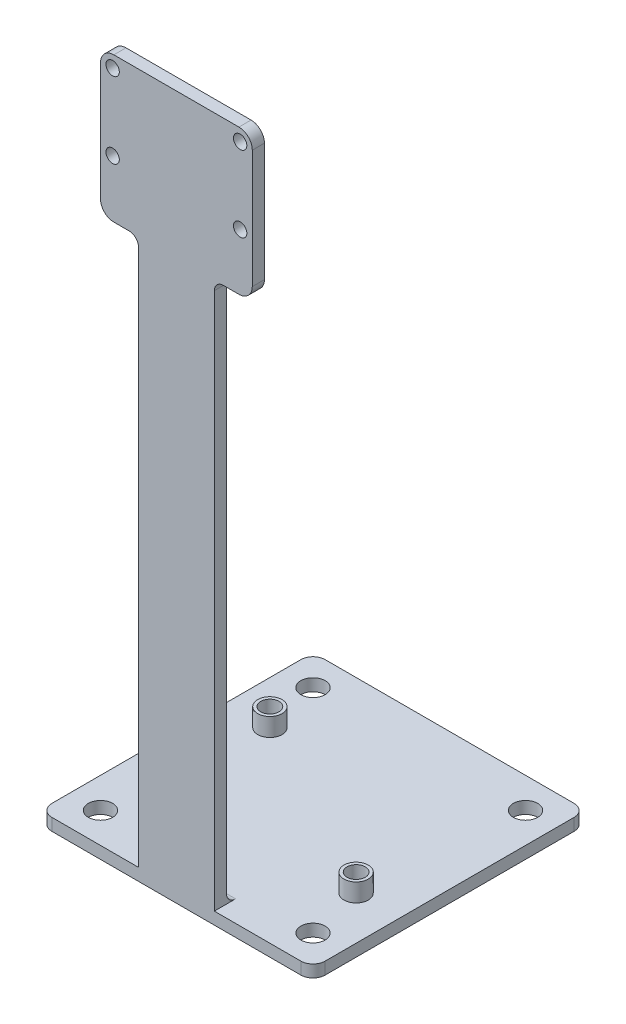
from build123d import *

# Parameters (mm, degrees)
SKETCH1_R           = 1.1
BOSS_EXTRUDE1_DEPTH = 2
FILLET1_R           = 2.2
FILLET2_R           = 2.2
FILLET3_R           = 2.2
FILLET5_R           = 2.2
FILLET6_R           = 1.5
FILLET7_R           = 1.5
SKETCH5_W           = 45
SKETCH5_H           = 45
SKETCH5_R           = 2
BOSS_EXTRUDE4_DEPTH = 2
FILLET17_R          = 2
FILLET18_R          = 2
FILLET19_R          = 2
FILLET20_R          = 2
FILLET21_R          = 1.5
SKETCH7_R           = 2
BOSS_EXTRUDE8_DEPTH = 5
SKETCH10_R          = 1.5
CUT_EXTRUDE4_DEPTH  = 6


with BuildPart() as part:
    # Sketch1 → Boss-Extrude1 (new body)
    with BuildSketch(Plane.XY):
        Polygon((6.25, 0), (6.25, -90), (18.75, -90), (18.75, 0), (25, 0), (25, 23.862), (0, 23.862), (0, 0), align=None)
        with Locations((2, 21.862)):
            Circle(SKETCH1_R, mode=Mode.SUBTRACT)
        with Locations((23, 21.862)):
            Circle(SKETCH1_R, mode=Mode.SUBTRACT)
        with Locations((2, 9.362)):
            Circle(SKETCH1_R, mode=Mode.SUBTRACT)
        with Locations((23, 9.362)):
            Circle(SKETCH1_R, mode=Mode.SUBTRACT)
    extrude(amount=BOSS_EXTRUDE1_DEPTH)

    # Fillet1
    fillet1_edges = [part.edges().sort_by_distance(p)[0] for p in [
        (0, 0, 1),
    ]]
    fillet(fillet1_edges, radius=FILLET1_R)

    # Fillet2
    fillet2_edges = [part.edges().sort_by_distance(p)[0] for p in [
        (0, 23.862, 1),
    ]]
    fillet(fillet2_edges, radius=FILLET2_R)

    # Fillet3
    fillet3_edges = [part.edges().sort_by_distance(p)[0] for p in [
        (25, 23.862, 1),
    ]]
    fillet(fillet3_edges, radius=FILLET3_R)

    # Fillet5
    fillet5_edges = [part.edges().sort_by_distance(p)[0] for p in [
        (25, 0, 1),
    ]]
    fillet(fillet5_edges, radius=FILLET5_R)

    # Fillet6
    fillet6_edges = [part.edges().sort_by_distance(p)[0] for p in [
        (18.75, 0, 1),
    ]]
    fillet(fillet6_edges, radius=FILLET6_R)

    # Fillet7
    fillet7_edges = [part.edges().sort_by_distance(p)[0] for p in [
        (6.25, 0, 1),
    ]]
    fillet(fillet7_edges, radius=FILLET7_R)

    # Sketch5 → Boss-Extrude4 (add)
    with BuildSketch(Plane.XZ.offset(90)):
        with Locations((12.5, -20.5)):
            Rectangle(SKETCH5_W, SKETCH5_H)
        with Locations((-5, -3)):
            Circle(SKETCH5_R, mode=Mode.SUBTRACT)
        with Locations((-5, -38)):
            Circle(SKETCH5_R, mode=Mode.SUBTRACT)
        with Locations((30, -3)):
            Circle(SKETCH5_R, mode=Mode.SUBTRACT)
        with Locations((30, -38)):
            Circle(SKETCH5_R, mode=Mode.SUBTRACT)
    extrude(amount=BOSS_EXTRUDE4_DEPTH)

    # Fillet17
    fillet17_edges = [part.edges().sort_by_distance(p)[0] for p in [
        (35, -91, 2),
    ]]
    fillet(fillet17_edges, radius=FILLET17_R)

    # Fillet18
    fillet18_edges = [part.edges().sort_by_distance(p)[0] for p in [
        (-10, -91, 2),
    ]]
    fillet(fillet18_edges, radius=FILLET18_R)

    # Fillet19
    fillet19_edges = [part.edges().sort_by_distance(p)[0] for p in [
        (-10, -91, -43),
    ]]
    fillet(fillet19_edges, radius=FILLET19_R)

    # Fillet20
    fillet20_edges = [part.edges().sort_by_distance(p)[0] for p in [
        (35, -91, -43),
    ]]
    fillet(fillet20_edges, radius=FILLET20_R)

    # Fillet21
    fillet21_edges = [part.edges().sort_by_distance(p)[0] for p in [
        (12.5, -90, 0),
    ]]
    fillet(fillet21_edges, radius=FILLET21_R)

    # Sketch7 → Boss-Extrude8 (add)
    with BuildSketch(Plane.XZ.offset(92)):
        with Locations((27.85, -12.25)):
            Circle(SKETCH7_R)
        with Locations((-2.85, -28.75)):
            Circle(SKETCH7_R)
    extrude(amount=-BOSS_EXTRUDE8_DEPTH)

    # Sketch10 → Cut-Extrude4 (cut, through all)
    with BuildSketch(Plane(origin=(0, -87, 0), x_dir=(1, 0, 0), z_dir=(0, 1, 0))):
        with Locations((27.85, 12.25)):
            Circle(SKETCH10_R)
        with Locations((-2.85, 28.75)):
            Circle(SKETCH10_R)
    extrude(amount=-CUT_EXTRUDE4_DEPTH, mode=Mode.SUBTRACT)


solid = part.part
